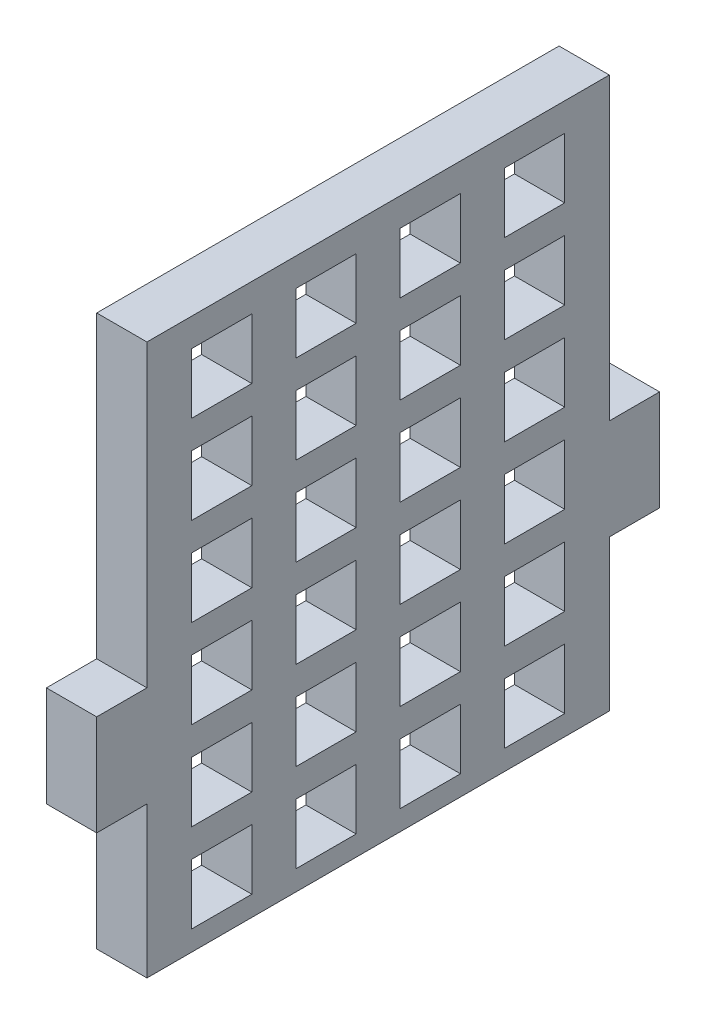
from build123d import *

# Parameters (mm, degrees)
SKETCH1_W          = 35.56
SKETCH1_H          = 41.148
EXTRUDE1_DEPTH     = 3.175
SKETCH2_W          = 3.175
SKETCH2_H          = 18.923
SKETCH2_H_2        = 15.875
CUT_EXTRUDE3_DEPTH = 4.175
SKETCH3_W          = 29.21
SKETCH3_H          = 6.35
CUT_EXTRUDE4_DEPTH = 4.175
SKETCH4_W          = 3.81
SKETCH4_H          = 3.81
CUT_EXTRUDE5_DEPTH = 4.175


with BuildPart() as part:
    # Sketch1 → Extrude1 (new body)
    with BuildSketch(Plane(origin=(0, 0, 0), x_dir=(0, 0, -1), z_dir=(1, 0, 0))):
        with Locations((17.78, 20.574)):
            Rectangle(SKETCH1_W, SKETCH1_H)
    extrude(amount=EXTRUDE1_DEPTH)

    # Sketch2 → Cut-Extrude3 (cut, through all)
    with BuildSketch(Plane(origin=(3.175, 0, 0), x_dir=(0, 0, -1), z_dir=(1, 0, 0))):
        with Locations((1.5875, 31.6865)):
            Rectangle(SKETCH2_W, SKETCH2_H)
        with Locations((33.9725, 31.6865)):
            Rectangle(SKETCH2_W, SKETCH2_H)
        with Locations((33.9725, 7.9375)):
            Rectangle(SKETCH2_W, SKETCH2_H_2)
        with Locations((1.5875, 7.9375)):
            Rectangle(SKETCH2_W, SKETCH2_H_2)
    extrude(amount=-CUT_EXTRUDE3_DEPTH, mode=Mode.SUBTRACT)

    # Sketch3 → Cut-Extrude4 (cut, through all)
    with BuildSketch(Plane(origin=(3.175, 0, 0), x_dir=(0, 0, -1), z_dir=(1, 0, 0))):
        with Locations((17.78, 3.175)):
            Rectangle(SKETCH3_W, SKETCH3_H)
    extrude(amount=-CUT_EXTRUDE4_DEPTH, mode=Mode.SUBTRACT)

    # Sketch4 → Cut-Extrude5 (cut, through all)
    with BuildSketch(Plane(origin=(3.175, 0, 0), x_dir=(0, 0, -1), z_dir=(1, 0, 0))):
        with Locations((14.485579349, 9.525)):
            Rectangle(SKETCH4_W, SKETCH4_H)
        with Locations((7.896738046, 9.525)):
            Rectangle(SKETCH4_W, SKETCH4_H)
        with Locations((21.074420651, 9.525)):
            Rectangle(SKETCH4_W, SKETCH4_H)
        with Locations((27.663261954, 9.525)):
            Rectangle(SKETCH4_W, SKETCH4_H)
        with Locations((14.485579349, 15.113)):
            Rectangle(SKETCH4_W, SKETCH4_H)
        with Locations((7.896738046, 15.113)):
            Rectangle(SKETCH4_W, SKETCH4_H)
        with Locations((21.074420651, 15.113)):
            Rectangle(SKETCH4_W, SKETCH4_H)
        with Locations((27.663261954, 15.113)):
            Rectangle(SKETCH4_W, SKETCH4_H)
        with Locations((14.485579349, 20.701)):
            Rectangle(SKETCH4_W, SKETCH4_H)
        with Locations((7.896738046, 20.701)):
            Rectangle(SKETCH4_W, SKETCH4_H)
        with Locations((21.074420651, 20.701)):
            Rectangle(SKETCH4_W, SKETCH4_H)
        with Locations((27.663261954, 20.701)):
            Rectangle(SKETCH4_W, SKETCH4_H)
        with Locations((14.485579349, 26.289)):
            Rectangle(SKETCH4_W, SKETCH4_H)
        with Locations((7.896738046, 26.289)):
            Rectangle(SKETCH4_W, SKETCH4_H)
        with Locations((21.074420651, 26.289)):
            Rectangle(SKETCH4_W, SKETCH4_H)
        with Locations((27.663261954, 26.289)):
            Rectangle(SKETCH4_W, SKETCH4_H)
        with Locations((14.485579349, 31.877)):
            Rectangle(SKETCH4_W, SKETCH4_H)
        with Locations((7.896738046, 31.877)):
            Rectangle(SKETCH4_W, SKETCH4_H)
        with Locations((21.074420651, 31.877)):
            Rectangle(SKETCH4_W, SKETCH4_H)
        with Locations((27.663261954, 31.877)):
            Rectangle(SKETCH4_W, SKETCH4_H)
        with Locations((14.485579349, 37.465)):
            Rectangle(SKETCH4_W, SKETCH4_H)
        with Locations((7.896738046, 37.465)):
            Rectangle(SKETCH4_W, SKETCH4_H)
        with Locations((21.074420651, 37.465)):
            Rectangle(SKETCH4_W, SKETCH4_H)
        with Locations((27.663261954, 37.465)):
            Rectangle(SKETCH4_W, SKETCH4_H)
    extrude(amount=-CUT_EXTRUDE5_DEPTH, mode=Mode.SUBTRACT)


solid = part.part
